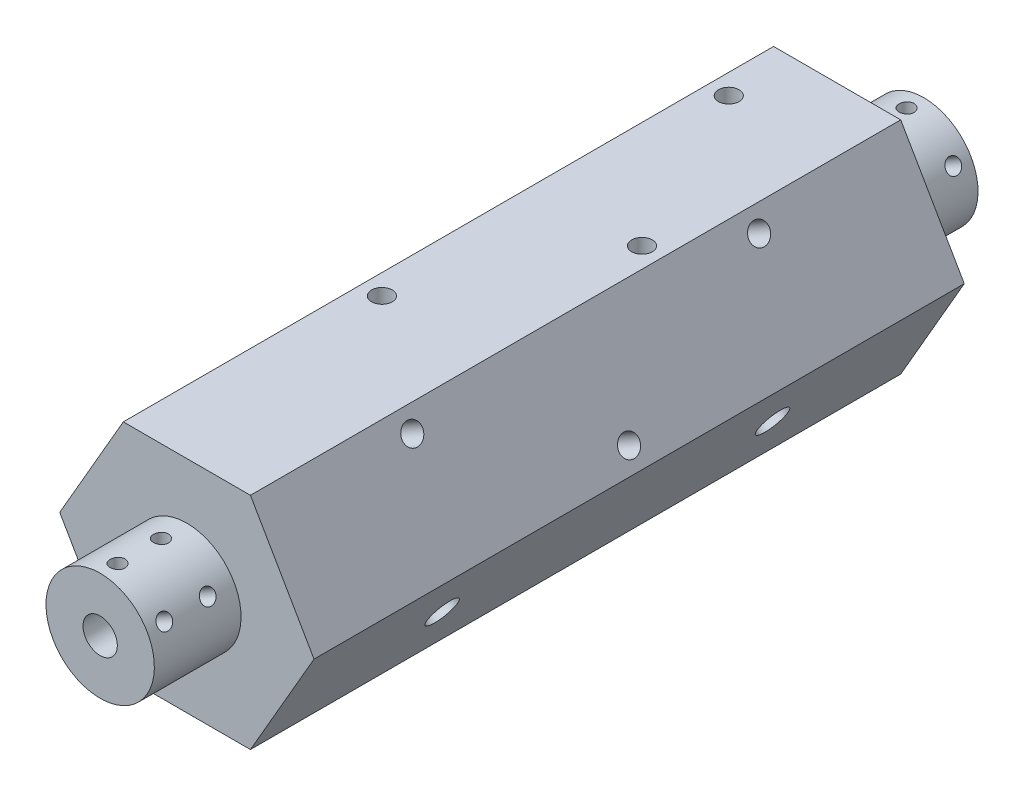
from build123d import *

# Parameters (mm, degrees)
BOSS_EXTRUDE1_DEPTH                          = 95
SKETCH7_W                                    = 20
SKETCH7_H                                    = 27.5
SKETCH7_W_2                                  = 23
SKETCH7_H_2                                  = 3.9575
F_8_32_TAPPED_HOLE1_REACH                    = 194.075
F_8_32_TAPPED_HOLE1_BORE_R                   = 1.7272
CIRPATTERN1_COUNT                            = 2
CIRPATTERN1_ANGLE                            = 60
MIRROR1_COPY_1_REACH                         = 194.075
MIRROR1_COPY_1_SKETCH_R                      = 1.7272
F_3_16_0_1875_DIAMETER_HOLE1_D               = 4.7625
F_3_16_0_1875_DIAMETER_HOLE1_DEPTH           = 15
F_3_16_0_1875_DIAMETER_HOLE1_TIP             = 2.38125
F_3_16_0_1875_DIAMETER_HOLE1_ON_FACE_2_D     = 4.7625
F_3_16_0_1875_DIAMETER_HOLE1_ON_FACE_2_DEPTH = 15
F_3_16_0_1875_DIAMETER_HOLE1_ON_FACE_2_TIP   = 2.38125
F_3_16_0_1875_DIAMETER_HOLE1_ON_FACE_3_D     = 4.7625
F_3_16_0_1875_DIAMETER_HOLE1_ON_FACE_3_DEPTH = 15
F_3_16_0_1875_DIAMETER_HOLE1_ON_FACE_3_TIP   = 2.38125
F_3_16_0_1875_DIAMETER_HOLE1_ON_FACE_4_D     = 4.7625
F_3_16_0_1875_DIAMETER_HOLE1_ON_FACE_4_DEPTH = 15
F_3_16_0_1875_DIAMETER_HOLE1_ON_FACE_4_TIP   = 2.38125
F_1_8_0_125_DIAMETER_HOLE1_D                 = 3.175
F_1_8_0_125_DIAMETER_HOLE1_DEPTH             = 4
F_1_8_0_125_DIAMETER_HOLE1_TIP               = 1.5875
F_1_4_CLEARANCE_HOLE1_D                      = 7.14248


with BuildPart() as part:
    # Sketch1 → Boss-Extrude1 (new, symmetric)
    with BuildSketch(Plane.XY):
        Polygon((-14.664696837, 25.4), (14.664696837, 25.4), (29.329393675, 0), (14.664696837, -25.4), (-14.664696837, -25.4), (-29.329393675, 0), align=None)
    extrude(amount=BOSS_EXTRUDE1_DEPTH, both=True)

    # Sketch4 → N (0.302) Diameter Hole1 (revolve, cut)
    with BuildSketch(Plane(origin=(0, 0, -95), x_dir=(0, 1, 0), z_dir=(1, 0, 0))):
        Polygon((0, 0), (0, 28.8354), (3.8354, 25), (3.8354, 0), align=None)
    n_0_302_diameter_hole1 = revolve(axis=Axis((0, 0, -101.35), (0, 0, 1)), mode=Mode.SUBTRACT)

    # Sketch7 → Cut-Revolve1 (revolve, cut)
    with BuildSketch(Plane(origin=(0, 0, 0), x_dir=(0, 0, -1), z_dir=(1, 0, 0))):
        with Locations((85, 26.25)):
            Rectangle(SKETCH7_W, SKETCH7_H)
        with Locations((83.5, 1.97875)):
            Rectangle(SKETCH7_W_2, SKETCH7_H_2)
    cut_revolve1 = revolve(axis=Axis((0, 0, -110.162380218), (0, 0, 1)), mode=Mode.SUBTRACT)

    # #8-32 Tapped Hole1 bore (on position points) → #8-32 Tapped Hole1 (cut, up to next)
    with BuildSketch(Plane(origin=(0, 12.5, -91), x_dir=(0, 0, 1), z_dir=(0, 1, 0)), mode=Mode.PRIVATE) as f_8_32_tapped_hole1_sk1:
        Circle(F_8_32_TAPPED_HOLE1_BORE_R)
    f_8_32_tapped_hole1_tool1 = extrude(f_8_32_tapped_hole1_sk1.sketch, amount=-F_8_32_TAPPED_HOLE1_REACH, mode=Mode.PRIVATE) & part.part
    # #8-32 Tapped Hole1 bore (on position points) → #8-32 Tapped Hole1 (cut, up to next)
    with BuildSketch(Plane(origin=(0, 12.5, -91), x_dir=(0, 0, 1), z_dir=(0, 1, 0)), mode=Mode.PRIVATE) as f_8_32_tapped_hole1_sk2:
        with Locations((10, 0)):
            Circle(F_8_32_TAPPED_HOLE1_BORE_R)
    f_8_32_tapped_hole1_tool2 = extrude(f_8_32_tapped_hole1_sk2.sketch, amount=-F_8_32_TAPPED_HOLE1_REACH, mode=Mode.PRIVATE) & part.part
    f_8_32_tapped_hole1_1 = f_8_32_tapped_hole1_tool1.solids().sort_by_distance((0, 12.5, -91))[0]
    add(f_8_32_tapped_hole1_1, mode=Mode.SUBTRACT)
    f_8_32_tapped_hole1_2 = f_8_32_tapped_hole1_tool2.solids().sort_by_distance((0, 12.5, -81))[0]
    add(f_8_32_tapped_hole1_2, mode=Mode.SUBTRACT)
    f_8_32_tapped_hole1 = f_8_32_tapped_hole1_1 + f_8_32_tapped_hole1_2  # #8-32 Tapped Hole1 as one shape, for the pattern or mirror that repeats it

    # CirPattern1: #8-32 Tapped Hole1 ×2 about axis
    cirpattern1_axis = Axis((0, 0, -110), (0, 0, -1))
    for i in range(1, CIRPATTERN1_COUNT):
        add(f_8_32_tapped_hole1.rotate(cirpattern1_axis, i * CIRPATTERN1_ANGLE / (CIRPATTERN1_COUNT - 1)), mode=Mode.SUBTRACT)

    # Mirror1: N (0.302) Diameter Hole1, Cut-Revolve1, #8-32 Tapped Hole1 across plane
    add(n_0_302_diameter_hole1.mirror(Plane.XY), mode=Mode.SUBTRACT)
    add(cut_revolve1.mirror(Plane.XY), mode=Mode.SUBTRACT)
    add(f_8_32_tapped_hole1.mirror(Plane.XY), mode=Mode.SUBTRACT)

    # Mirror1 copy 1 sketch → Mirror1 copy 1 (cut, up to next)
    with BuildSketch(Plane(origin=(10.825317547, 6.25, 91), x_dir=(0, 0, -1), z_dir=(0.8660254037844398, 0.499999999999998, 0)), mode=Mode.PRIVATE) as mirror1_copy_1_sk1:
        Circle(MIRROR1_COPY_1_SKETCH_R)
    mirror1_copy_1_tool1 = extrude(mirror1_copy_1_sk1.sketch, amount=-MIRROR1_COPY_1_REACH, mode=Mode.PRIVATE) & part.part
    # Mirror1 copy 1 sketch → Mirror1 copy 1 (cut, up to next)
    with BuildSketch(Plane(origin=(10.825317547, 6.25, 91), x_dir=(0, 0, -1), z_dir=(0.8660254037844398, 0.499999999999998, 0)), mode=Mode.PRIVATE) as mirror1_copy_1_sk2:
        with Locations((10, 0)):
            Circle(MIRROR1_COPY_1_SKETCH_R)
    mirror1_copy_1_tool2 = extrude(mirror1_copy_1_sk2.sketch, amount=-MIRROR1_COPY_1_REACH, mode=Mode.PRIVATE) & part.part
    add(mirror1_copy_1_tool1.solids().sort_by_distance((10.825317547, 6.25, 91))[0], mode=Mode.SUBTRACT)
    add(mirror1_copy_1_tool2.solids().sort_by_distance((10.825317547, 6.25, 81))[0], mode=Mode.SUBTRACT)

    # 3/16 (0.1875) Diameter Hole1
    with Locations(Plane(origin=(-10, 25.4, 20), x_dir=(1, 0, 0), z_dir=(0, 1, 0))):
        with Locations((0, 0), (0, 80), (20, 40)):
            Hole(F_3_16_0_1875_DIAMETER_HOLE1_D / 2, depth=F_3_16_0_1875_DIAMETER_HOLE1_DEPTH)
            with Locations((0, 0, -(F_3_16_0_1875_DIAMETER_HOLE1_DEPTH + F_3_16_0_1875_DIAMETER_HOLE1_TIP / 2))):  # 90° drill point
                Cone(0, F_3_16_0_1875_DIAMETER_HOLE1_D / 2, F_3_16_0_1875_DIAMETER_HOLE1_TIP, mode=Mode.SUBTRACT)

    # 3/16 (0.1875) Diameter Hole1 on face 2
    with Locations(Plane(origin=(26.997045256, 4.039745962, 0), x_dir=(-0.500000174844, 0.866025302838, 0), z_dir=(0.866025302838, 0.500000174844, 0))):
        with Locations((0, 0)):
            Hole(F_3_16_0_1875_DIAMETER_HOLE1_ON_FACE_2_D / 2, depth=F_3_16_0_1875_DIAMETER_HOLE1_ON_FACE_2_DEPTH)
            with Locations((0, 0, -(F_3_16_0_1875_DIAMETER_HOLE1_ON_FACE_2_DEPTH + F_3_16_0_1875_DIAMETER_HOLE1_ON_FACE_2_TIP / 2))):  # 90° drill point
                Cone(0, F_3_16_0_1875_DIAMETER_HOLE1_ON_FACE_2_D / 2, F_3_16_0_1875_DIAMETER_HOLE1_ON_FACE_2_TIP, mode=Mode.SUBTRACT)

    # 3/16 (0.1875) Diameter Hole1 on face 3
    with Locations(Plane(origin=(16.997045256, 21.360254038, -40), x_dir=(-0.500000174844, 0.866025302838, 0), z_dir=(0.866025302838, 0.500000174844, 0))):
        with Locations((0, 0), (0, 80)):
            Hole(F_3_16_0_1875_DIAMETER_HOLE1_ON_FACE_3_D / 2, depth=F_3_16_0_1875_DIAMETER_HOLE1_ON_FACE_3_DEPTH)
            with Locations((0, 0, -(F_3_16_0_1875_DIAMETER_HOLE1_ON_FACE_3_DEPTH + F_3_16_0_1875_DIAMETER_HOLE1_ON_FACE_3_TIP / 2))):  # 90° drill point
                Cone(0, F_3_16_0_1875_DIAMETER_HOLE1_ON_FACE_3_D / 2, F_3_16_0_1875_DIAMETER_HOLE1_ON_FACE_3_TIP, mode=Mode.SUBTRACT)

    # 3/16 (0.1875) Diameter Hole1 on face 4
    with Locations(Plane(origin=(10, -25.4, -20), x_dir=(0, 0, -1), z_dir=(0, -1, 0))):
        with Locations((0, 0), (-40, -20), (-80, 0)):
            Hole(F_3_16_0_1875_DIAMETER_HOLE1_ON_FACE_4_D / 2, depth=F_3_16_0_1875_DIAMETER_HOLE1_ON_FACE_4_DEPTH)
            with Locations((0, 0, -(F_3_16_0_1875_DIAMETER_HOLE1_ON_FACE_4_DEPTH + F_3_16_0_1875_DIAMETER_HOLE1_ON_FACE_4_TIP / 2))):  # 90° drill point
                Cone(0, F_3_16_0_1875_DIAMETER_HOLE1_ON_FACE_4_D / 2, F_3_16_0_1875_DIAMETER_HOLE1_ON_FACE_4_TIP, mode=Mode.SUBTRACT)

    # 1/8 (0.125) Diameter Hole1
    with Locations(Plane(origin=(0, 0, -75), x_dir=(-1, 0, 0), z_dir=(0, 0, -1))):
        with Locations((10, 20)):
            Hole(F_1_8_0_125_DIAMETER_HOLE1_D / 2, depth=F_1_8_0_125_DIAMETER_HOLE1_DEPTH)
            with Locations((0, 0, -(F_1_8_0_125_DIAMETER_HOLE1_DEPTH + F_1_8_0_125_DIAMETER_HOLE1_TIP / 2))):  # 90° drill point
                Cone(0, F_1_8_0_125_DIAMETER_HOLE1_D / 2, F_1_8_0_125_DIAMETER_HOLE1_TIP, mode=Mode.SUBTRACT)

    # 1/4 Clearance Hole1 (through all)
    with Locations(Plane(origin=(-21.997045256, 12.7, 0), x_dir=(0, 0, 1), z_dir=(-0.8660254037844365, 0.500000000000004, 0))):
        with Locations((38.1, 0), (-38.1, 0)):
            Hole(F_1_4_CLEARANCE_HOLE1_D / 2)


solid = part.part
